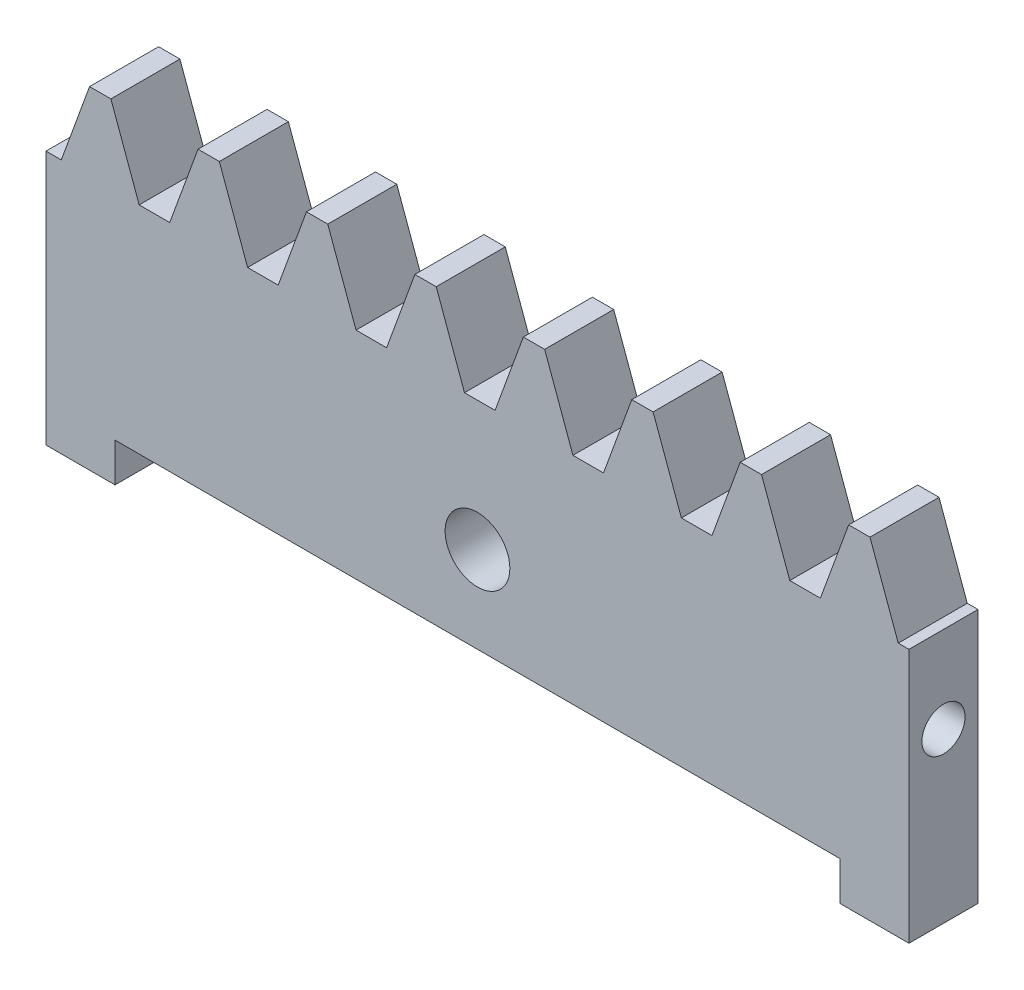
from build123d import *

# Parameters (mm, degrees)
BLANKSKE_W          = 127
BLANKSKE_H          = 43.18
BLANK_DEPTH         = 10.16
TOOTHCUTSIM_DEPTH   = 135.524116797
TEETHCUTS_COUNT     = 9
TEETHCUTS_PITCH     = 15.959290662
SKETCH4_R           = 3.175
CUT_EXTRUDE2_DEPTH  = 135.524116797
SKETCH1_W           = 10.16
SKETCH1_H           = 10.16
BOSS_EXTRUDE1_DEPTH = 5.715
SKETCH5_R           = 4.7625
CUT_EXTRUDE3_DEPTH  = 135.524116797


with BuildPart() as part:
    # BlankSke → Blank (new body)
    with BuildSketch(Plane.XY):
        with Locations((63.5, 21.59)):
            Rectangle(BLANKSKE_W, BLANKSKE_H)
    extrude(amount=-BLANK_DEPTH)

    # TooCutSkeSim → ToothCutSim (cut, through all)
    with BuildSketch(Plane.XY):
        Polygon((2.250111678, 31.75), (-2.250111678, 31.75), (-6.4195363, 43.2054), (6.4195363, 43.2054), align=None)
    toothcutsim = extrude(amount=-TOOTHCUTSIM_DEPTH, mode=Mode.SUBTRACT)

    # TeethCuts: ToothCutSim ×9
    with Locations(*[(i * TEETHCUTS_PITCH, 0, 0) for i in range(1, TEETHCUTS_COUNT)]):
        add(toothcutsim, mode=Mode.SUBTRACT)

    # Sketch4 → Cut-Extrude2 (cut, through all)
    with BuildSketch(Plane.ZY):
        with Locations((-5.08, 19.05)):
            Circle(SKETCH4_R)
    extrude(amount=-CUT_EXTRUDE2_DEPTH, mode=Mode.SUBTRACT)

    # Sketch1 → Boss-Extrude1 (add)
    with BuildSketch(Plane.XZ):
        with Locations((5.08, -5.08)):
            Rectangle(SKETCH1_W, SKETCH1_H)
        with Locations((121.92, -5.08)):
            Rectangle(SKETCH1_W, SKETCH1_H)
    extrude(amount=BOSS_EXTRUDE1_DEPTH)

    # Sketch5 → Cut-Extrude3 (cut, through all)
    with BuildSketch(Plane.XY):
        with Locations((63.5, 12.7)):
            Circle(SKETCH5_R)
    extrude(amount=-CUT_EXTRUDE3_DEPTH, mode=Mode.SUBTRACT)


solid = part.part
